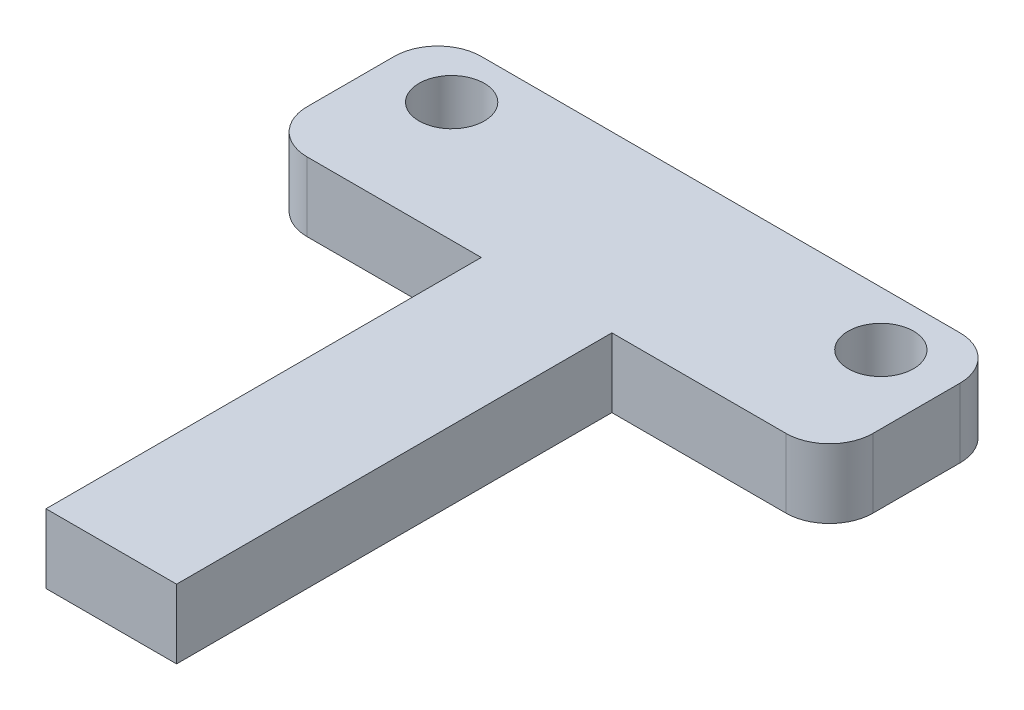
from build123d import *

# Parameters (mm, degrees)
SKETCH_1_R      = 1.5
EXTRUDE_1_DEPTH = 3.175


with BuildPart() as part:
    # 草图1 → 凸台-拉伸1 (new body)
    with BuildSketch(Plane(origin=(0, 0, 0), x_dir=(1, 0, 0), z_dir=(0, 1, 0))):
        with BuildLine():
            Line((-11, 4), (11, 4))
            ThreePointArc((11, 4), (12.414213562, 3.414213562), (13, 2))
            Line((13, 2), (13, -2))
            ThreePointArc((13, -2), (12.414213562, -3.414213562), (11, -4))
            Line((11, -4), (3, -4))
            Line((3, -4), (3, -24))
            Line((3, -24), (-3, -24))
            Line((-3, -24), (-3, -4))
            Line((-3, -4), (-11, -4))
            ThreePointArc((-11, -4), (-12.414213562, -3.414213562), (-13, -2))
            Line((-13, -2), (-13, 2))
            ThreePointArc((-13, 2), (-12.414213562, 3.414213562), (-11, 4))
        make_face()
        with Locations((-9.86, 1.5)):
            Circle(SKETCH_1_R, mode=Mode.SUBTRACT)
        with Locations((9.86, 1.5)):
            Circle(SKETCH_1_R, mode=Mode.SUBTRACT)
    extrude(amount=EXTRUDE_1_DEPTH)


solid = part.part
